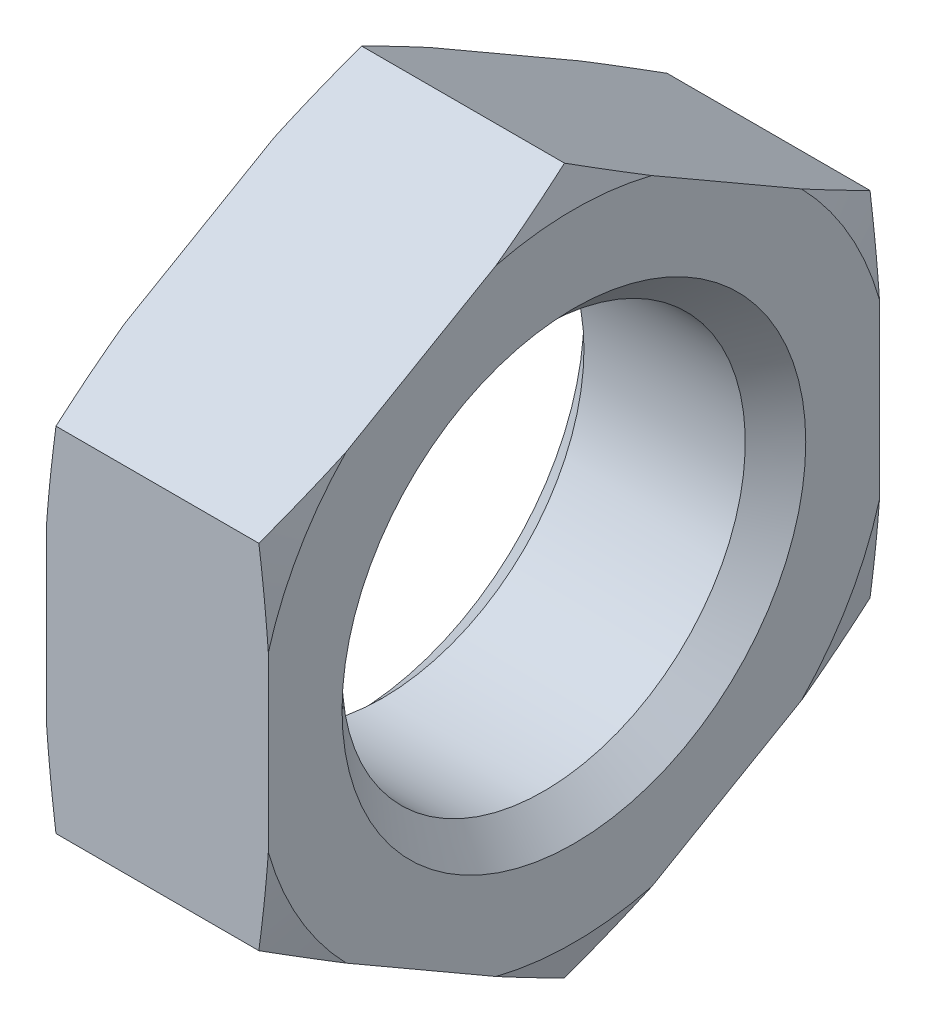
from build123d import *

# Parameters (mm, degrees)
SKETCH_5_OUTSIDE_W  = 11.028
SKETCH_5_OUTSIDE_H  = 11.028
CUT_EXTRUDE_6_DEPTH = 1.1
CHAMFER_4_SIZE      = 0.3


with BuildPart() as part:
    # Эскиз3 → Повернуть1 (revolve)
    with BuildSketch(Plane.XY):
        Polygon((1.1, 2), (1.1, 3.15), (1.006217783, 3.5), (-1.006217783, 3.5), (-1.1, 3.15), (-1.1, 2), align=None)
    revolve(axis=Axis((-2.78527838, 0, 0), (1, 0, 0)))

    # Эскиз5 outside → Вырез-Вытянуть6 (cut, symmetric)
    with BuildSketch(Plane(origin=(0, 0, 0), x_dir=(0, 0, -1), z_dir=(1, 0, 0))):
        Rectangle(SKETCH_5_OUTSIDE_W, SKETCH_5_OUTSIDE_H)
        Polygon((0, 3.5), (-3.031088913, 1.75), (-3.031088913, -1.75), (0, -3.5), (3.031088913, -1.75), (3.031088913, 1.75), align=None, mode=Mode.SUBTRACT)
    extrude(amount=CUT_EXTRUDE_6_DEPTH, both=True, mode=Mode.SUBTRACT)

    # Фаска4
    chamfer_4_edges = [part.edges().sort_by_distance(p)[0] for p in [
        (-1.1, -2, 0),
        (1.1, -2, 0),
    ]]
    chamfer(chamfer_4_edges, length=CHAMFER_4_SIZE)


solid = part.part
